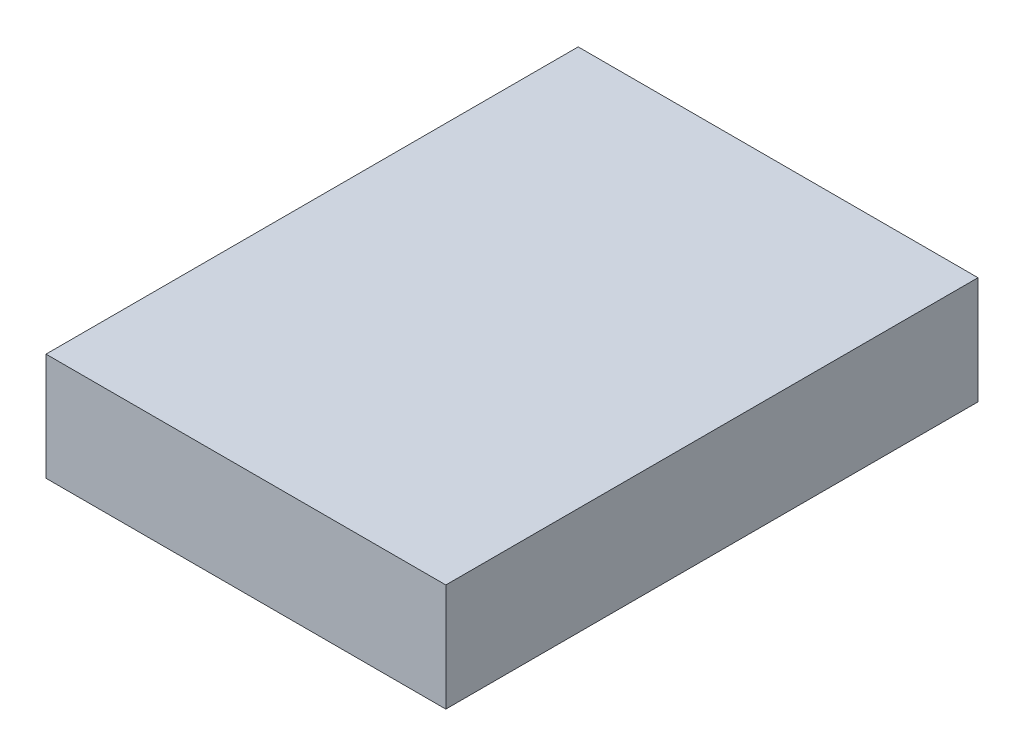
from build123d import *

# Parameters (mm, degrees)
SKETCH1_W           = 72.5
SKETCH1_H           = 96.5
BOSS_EXTRUDE1_DEPTH = 19.5


with BuildPart() as part:
    # Sketch1 → Boss-Extrude1 (new body)
    with BuildSketch(Plane(origin=(0, 0, 0), x_dir=(1, 0, 0), z_dir=(0, 1, 0))):
        with Locations((36.25, 48.25)):
            Rectangle(SKETCH1_W, SKETCH1_H)
    extrude(amount=BOSS_EXTRUDE1_DEPTH)


solid = part.part
